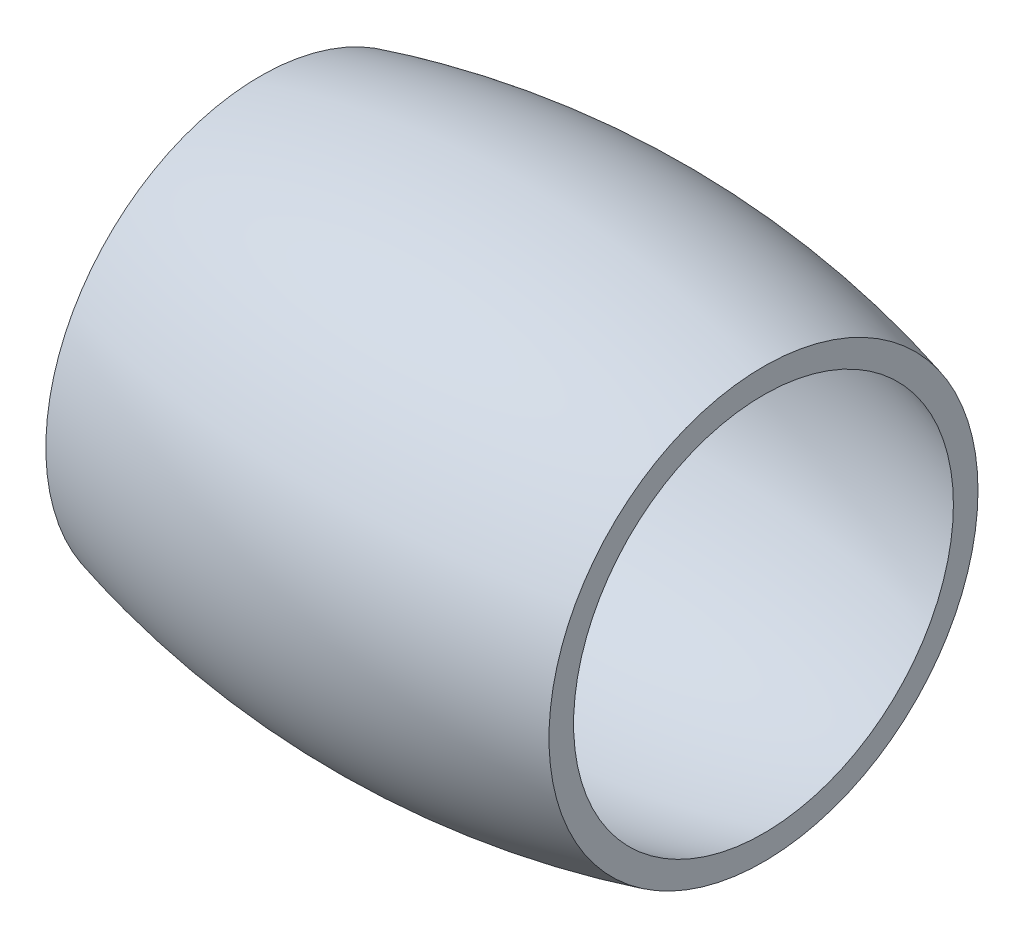
from build123d import *


with BuildPart() as part:
    # Sketch2 → Revolve1 (revolve)
    with BuildSketch(Plane.XY):
        with BuildLine():
            Line((-16.823237932, 12.7), (-16.823237932, 14.344980625))
            ThreePointArc((-16.823237932, 14.344980625), (0, 16.559801916), (16.823237932, 14.344980625))
            Line((16.823237932, 14.344980625), (16.823237932, 12.7))
            ThreePointArc((16.823237932, 12.7), (0, 14.972301916), (-16.823237932, 12.7))
        make_face()
    revolve(axis=Axis((27.966961403, 0, 0), (-1, 0, 0)))


solid = part.part
